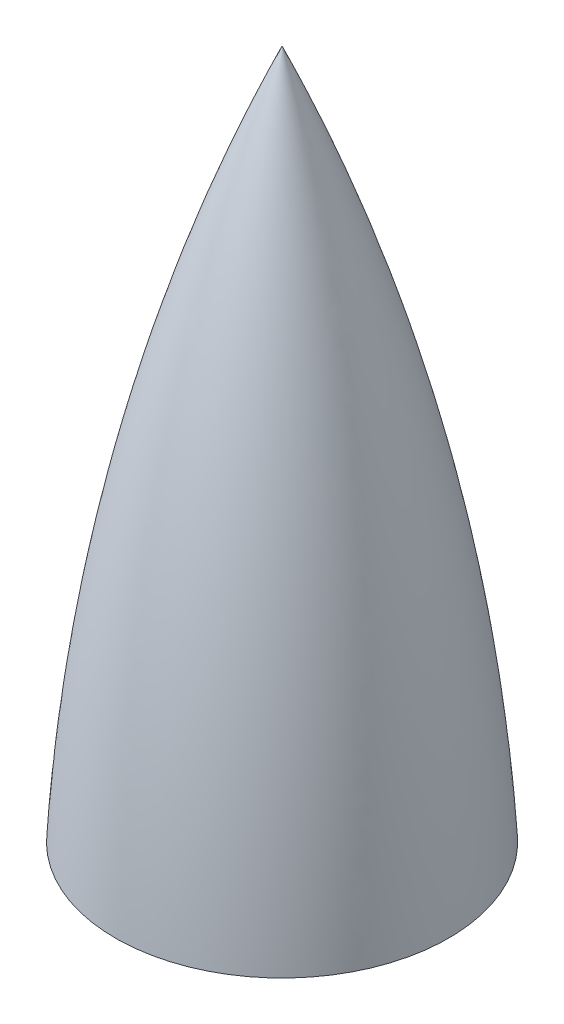
from build123d import *


with BuildPart() as part:
    # Sketch2 → Revolve1 (revolve)
    with BuildSketch(Plane.XY):
        with BuildLine():
            Line((-92.075, 0), (-88.9, 0))
            ThreePointArc((-88.9, 0), (-59.590343886, 191.54048673), (0, 375.92))
            Line((0, 375.92), (0, 381))
            ThreePointArc((0, 381), (-63.250367838, 194.659776394), (-92.075, 0))
        make_face()
    revolve(axis=Axis((0, 381, 0), (0, -1, 0)))


solid = part.part
